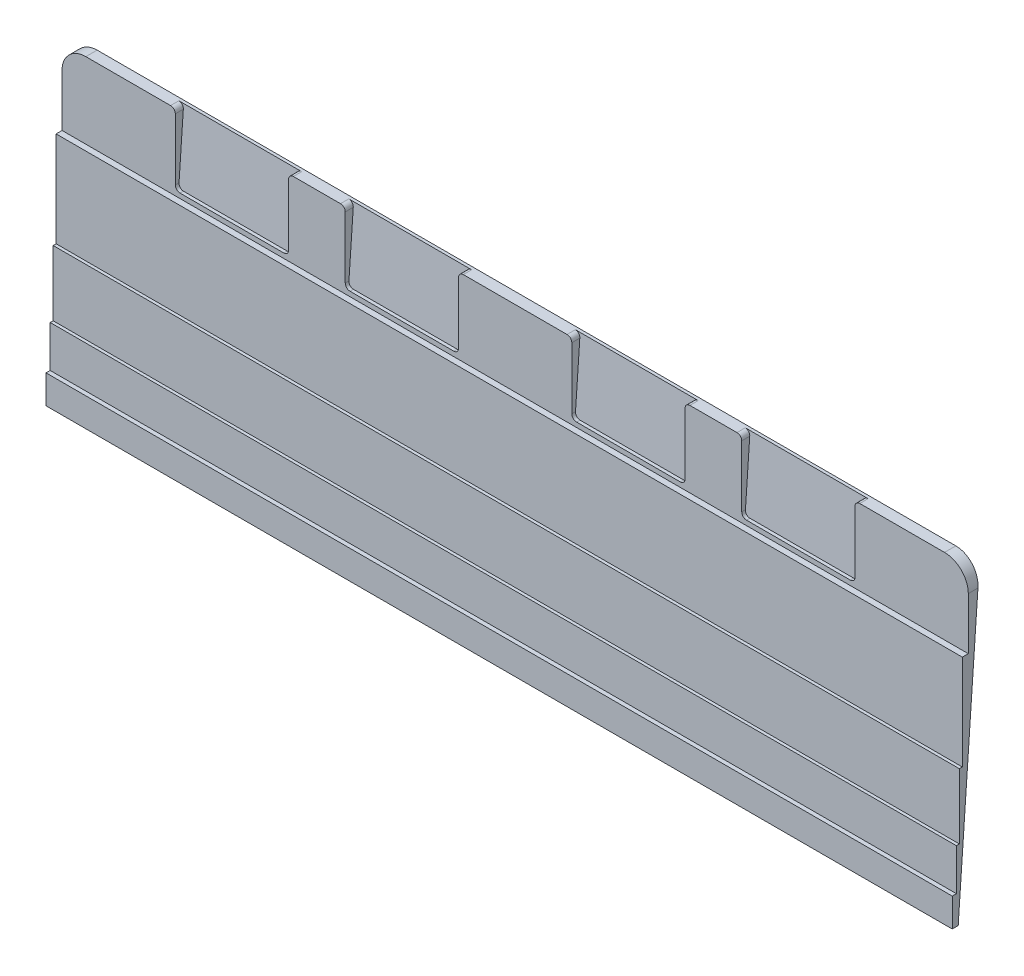
from build123d import *

# Parameters (mm, degrees)
BOSS_EXTRUDE1_DEPTH              = 304.800275
FILLET1_R                        = 8
CUT_EXTRUDE1_REACH               = 6.806
CUT_EXTRUDE1_OFFSET_FROM_SURFACE = 1
SKETCH2_W                        = 38.10085
SKETCH2_H                        = 23.904524524
SKETCH2_W_2                      = 38.1
FILLET2_R                        = 1.6
FILLET3_R                        = 1.6


with BuildPart() as part:
    # Sketch1 → Boss-Extrude1 (new body)
    with BuildSketch(Plane.ZY.offset(149.225)):
        Polygon((-2, -64.023653), (-3.3962, -64.023653), (-3.3962, -50.048837521), (-4.3962, -50.048837521), (-4.3962, -28.126347), (-5.3962, -28.126347), (-5.3962, 3.873653), (-7.3962, 3.873653), (-7.3962, 29.378177524), (-11.202667042, 29.378177524), (-4, -73.62476), (-2, -73.62476), align=None)
    extrude(amount=-BOSS_EXTRUDE1_DEPTH)

    # Fillet1
    fillet1_edges = [part.edges().sort_by_distance(p)[0] for p in [
        (-149.225, 29.378177524, -9.299433521),
        (155.575275, 29.378177524, -9.299433521),
    ]]
    fillet(fillet1_edges, radius=FILLET1_R)

    # Cut-Extrude1: up to this face of the body (flat: up to its plane, moved by the offset)
    cut_extrude1_end = Plane(part.part.faces().sort_by_distance((3.1751375, -22.166826572, -7.598289234))[0]).offset(-CUT_EXTRUDE1_OFFSET_FROM_SURFACE)
    # Sketch2 → Cut-Extrude1 (cut, up to the picked face)
    with BuildSketch(Plane.XY.offset(-7.3962), mode=Mode.PRIVATE) as cut_extrude1_sk1:
        with Locations((41.2757, 17.425915262)):
            Rectangle(SKETCH2_W, SKETCH2_H)
    cut_extrude1_tool1 = split(extrude(cut_extrude1_sk1.sketch, amount=-CUT_EXTRUDE1_REACH, mode=Mode.PRIVATE), bisect_by=cut_extrude1_end, keep=Keep.BOTH, mode=Mode.PRIVATE)
    add(cut_extrude1_tool1.solids().sort_by_distance((41.2757, 17.425915, -7.3962))[0], mode=Mode.SUBTRACT)
    # Sketch2 → Cut-Extrude1 (cut, up to the picked face)
    with BuildSketch(Plane.XY.offset(-7.3962), mode=Mode.PRIVATE) as cut_extrude1_sk2:
        with Locations((-92.074875, 17.425915262)):
            Rectangle(SKETCH2_W_2, SKETCH2_H)
    cut_extrude1_tool2 = split(extrude(cut_extrude1_sk2.sketch, amount=-CUT_EXTRUDE1_REACH, mode=Mode.PRIVATE), bisect_by=cut_extrude1_end, keep=Keep.BOTH, mode=Mode.PRIVATE)
    add(cut_extrude1_tool2.solids().sort_by_distance((-92.074875, 17.425915, -7.3962))[0], mode=Mode.SUBTRACT)
    # Sketch2 → Cut-Extrude1 (cut, up to the picked face)
    with BuildSketch(Plane.XY.offset(-7.3962), mode=Mode.PRIVATE) as cut_extrude1_sk3:
        with Locations((-34.92515, 17.425915262)):
            Rectangle(SKETCH2_W, SKETCH2_H)
    cut_extrude1_tool3 = split(extrude(cut_extrude1_sk3.sketch, amount=-CUT_EXTRUDE1_REACH, mode=Mode.PRIVATE), bisect_by=cut_extrude1_end, keep=Keep.BOTH, mode=Mode.PRIVATE)
    add(cut_extrude1_tool3.solids().sort_by_distance((-34.92515, 17.425915, -7.3962))[0], mode=Mode.SUBTRACT)
    # Sketch2 → Cut-Extrude1 (cut, up to the picked face)
    with BuildSketch(Plane.XY.offset(-7.3962), mode=Mode.PRIVATE) as cut_extrude1_sk4:
        with Locations((98.425425, 17.425915262)):
            Rectangle(SKETCH2_W_2, SKETCH2_H)
    cut_extrude1_tool4 = split(extrude(cut_extrude1_sk4.sketch, amount=-CUT_EXTRUDE1_REACH, mode=Mode.PRIVATE), bisect_by=cut_extrude1_end, keep=Keep.BOTH, mode=Mode.PRIVATE)
    add(cut_extrude1_tool4.solids().sort_by_distance((98.425425, 17.425915, -7.3962))[0], mode=Mode.SUBTRACT)

    # Fillet2
    fillet2_edges = [part.edges().sort_by_distance(p)[0] for p in [
        (-73.024875, 5.473653, -7.962428976),
        (-111.124875, 5.473653, -7.962428976),
        (-15.874725, 5.473653, -7.962428976),
        (-53.975575, 5.473653, -7.962428976),
        (22.225275, 5.473653, -7.962428976),
        (60.326125, 5.473653, -7.962428976),
        (79.375425, 5.473653, -7.962428976),
        (117.475425, 5.473653, -7.962428976),
    ]]
    fillet(fillet2_edges, radius=FILLET2_R)

    # Fillet3
    fillet3_edges = [part.edges().sort_by_distance(p)[0] for p in [
        (-73.024875, 29.378177524, -8.798212572),
        (-111.124875, 29.378177524, -8.798212572),
        (-15.874725, 29.378177524, -8.798212572),
        (-53.975575, 29.378177524, -8.798212572),
        (60.326125, 29.378177524, -8.798212572),
        (22.225275, 29.378177524, -8.798212572),
        (117.475425, 29.378177524, -8.798212572),
        (79.375425, 29.378177524, -8.798212572),
    ]]
    fillet(fillet3_edges, radius=FILLET3_R)


solid = part.part
